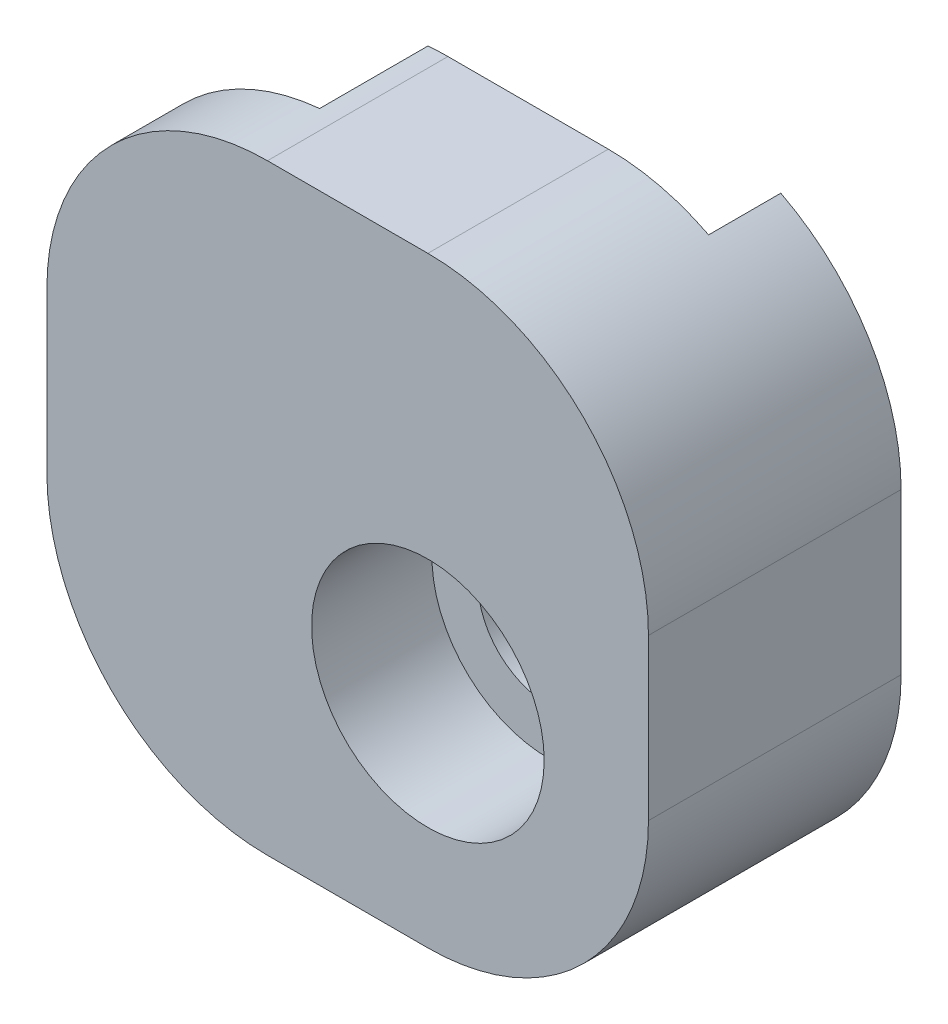
from build123d import *

# Parameters (mm, degrees)
ESBO_O3_W                = 7
ESBO_O3_H                = 12
ESBO_O3_R                = 1.75
RESSALTO_EXTRUS_O2_DEPTH = 2.7
ESBO_O4_W                = 7
ESBO_O4_H                = 12
ESBO_O4_R                = 1.75
RESSALTO_EXTRUS_O3_DEPTH = 2.1
ESBO_O5_W                = 2.1
ESBO_O5_H                = 12
RESSALTO_EXTRUS_O4_DEPTH = 5
RESSALTO_EXTRUS_O5_DEPTH = 3
ESBO_O7_W                = 4.8
ESBO_O7_H                = 15
RESSALTO_EXTRUS_O6_DEPTH = 3
ESBO_O8_R                = 2.9
CORTE_EXTRUS_O1_DEPTH    = 3
FILETE1_R                = 5.5
RESSALTO_EXTRUS_O7_DEPTH = 1.5
CORTE_EXTRUS_O4_DEPTH    = 6.3
CORTE_EXTRUS_O5_DEPTH    = 6.3
RESSALTO_EXTRUS_O8_DEPTH = 0.3
CORTE_EXTRUS_O6_DEPTH    = 0.3
ESBO_O17_R               = 2.9
CORTE_EXTRUS_O7_DEPTH    = 0.3


with BuildPart() as part:
    # Esboço3 → Ressalto-extrusão2 (new body)
    with BuildSketch(Plane.XY):
        with Locations((-3.5, 6)):
            Rectangle(ESBO_O3_W, ESBO_O3_H)
        with Locations((-2.5, 2.5)):
            Circle(ESBO_O3_R, mode=Mode.SUBTRACT)
    extrude(amount=RESSALTO_EXTRUS_O2_DEPTH)

    # Esboço4 → Ressalto-extrusão3 (add)
    with BuildSketch(Plane.XY.offset(2.7)):
        with Locations((-3.5, 6)):
            Rectangle(ESBO_O4_W, ESBO_O4_H)
        with Locations((-2.5, 2.5)):
            Circle(ESBO_O4_R, mode=Mode.SUBTRACT)
    extrude(amount=RESSALTO_EXTRUS_O3_DEPTH)

    # Esboço5 → Ressalto-extrusão4 (add)
    with BuildSketch(Plane.ZY.offset(7)):
        with Locations((3.75, 6)):
            Rectangle(ESBO_O5_W, ESBO_O5_H)
    extrude(amount=RESSALTO_EXTRUS_O4_DEPTH)

    # Esboço6 → Ressalto-extrusão5 (add)
    with BuildSketch(Plane.XZ):
        Polygon((-7, 0), (0, 0), (0, 4.8), (-12, 4.8), (-12, 2.7), (-7, 2.7), align=None)
    extrude(amount=RESSALTO_EXTRUS_O5_DEPTH)

    # Esboço7 → Ressalto-extrusão6 (add)
    with BuildSketch(Plane(origin=(0, 0, 0), x_dir=(0, 0, -1), z_dir=(1, 0, 0))):
        with Locations((-2.4, 4.5)):
            Rectangle(ESBO_O7_W, ESBO_O7_H)
    extrude(amount=RESSALTO_EXTRUS_O6_DEPTH)

    # Esboço8 → Corte-extrusão1 (cut)
    with BuildSketch(Plane.XY.offset(4.8)):
        with Locations((-2.5, 2.5)):
            Circle(ESBO_O8_R)
    extrude(amount=-CORTE_EXTRUS_O1_DEPTH, mode=Mode.SUBTRACT)

    # Filete1
    filete1_edges = [part.edges().sort_by_distance(p)[0] for p in [
        (3, -3, 2.4),
    ]]
    fillet(filete1_edges, radius=FILETE1_R)

    # Esboço10 → Ressalto-extrusão7 (add)
    with BuildSketch(Plane(origin=(0, 0, 0), x_dir=(-1, 0, 0), z_dir=(0, 0, -1))):
        with BuildLine():
            Line((7, 0), (0, 0))
            Line((0, 0), (0, 12))
            Line((0, 12), (-3, 12))
            Line((-3, 12), (-3, 2.5))
            ThreePointArc((-3, 2.5), (-1.389087297, -1.389087297), (2.5, -3))
            Line((2.5, -3), (7, -3))
            Line((7, -3), (7, 0))
        make_face()
    extrude(amount=RESSALTO_EXTRUS_O7_DEPTH)

    # Esboço14 → Corte-extrusão4 (cut)
    with BuildSketch(Plane.XY.offset(4.8)):
        with BuildLine():
            Line((-12, 12), (-12, 6.5))
            ThreePointArc((-12, 6.5), (-10.389087297, 10.389087297), (-6.5, 12))
            Line((-6.5, 12), (-12, 12))
        make_face()
        with BuildLine():
            ThreePointArc((-2.5, 12), (1.389087297, 10.389087297), (3, 6.5))
            Line((3, 6.5), (3, 12))
            Line((3, 12), (-2.5, 12))
        make_face()
    extrude(amount=-CORTE_EXTRUS_O4_DEPTH, mode=Mode.SUBTRACT)

    # Esboço13 → Corte-extrusão5 (cut)
    with BuildSketch(Plane.XY.offset(4.8)):
        with BuildLine():
            Line((-12, -3), (-6.5, -3))
            ThreePointArc((-6.5, -3), (-10.389087297, -1.389087297), (-12, 2.5))
            Line((-12, 2.5), (-12, -3))
        make_face()
    extrude(amount=-CORTE_EXTRUS_O5_DEPTH, mode=Mode.SUBTRACT)

    # Esboço15 → Ressalto-extrusão8 (add)
    with BuildSketch(Plane(origin=(0, 0, -1.5), x_dir=(-1, 0, 0), z_dir=(0, 0, -1))):
        with BuildLine():
            Line((2.5, -3), (6.5, -3))
            ThreePointArc((6.5, -3), (6.750259203, -2.994303444), (7, -2.977225575))
            Line((7, -2.977225575), (7, 0))
            Line((7, 0), (0, 0))
            Line((0, 0), (0, 11.398979486))
            ThreePointArc((0, 11.398979486), (-2.19041576, 9.372281323), (-3, 6.5))
            Line((-3, 6.5), (-3, 2.5))
            ThreePointArc((-3, 2.5), (-1.389087297, -1.389087297), (2.5, -3))
        make_face()
    extrude(amount=RESSALTO_EXTRUS_O8_DEPTH)

    # Esboço16 → Corte-extrusão6 (cut)
    with BuildSketch(Plane.XY.offset(4.8)):
        with BuildLine():
            Line((-12, 6.5), (-12, 2.5))
            ThreePointArc((-12, 2.5), (-10.389087297, -1.389087297), (-6.5, -3))
            Line((-6.5, -3), (-2.5, -3))
            ThreePointArc((-2.5, -3), (1.389087297, -1.389087297), (3, 2.5))
            Line((3, 2.5), (3, 6.5))
            ThreePointArc((3, 6.5), (1.389087297, 10.389087297), (-2.5, 12))
            Line((-2.5, 12), (-6.5, 12))
            ThreePointArc((-6.5, 12), (-10.389087297, 10.389087297), (-12, 6.5))
        make_face()
    extrude(amount=-CORTE_EXTRUS_O6_DEPTH, mode=Mode.SUBTRACT)

    # Esboço17 → Corte-extrusão7 (cut)
    with BuildSketch(Plane.XY.offset(1.8)):
        with Locations((-2.5, 2.5)):
            Circle(ESBO_O17_R)
    extrude(amount=-CORTE_EXTRUS_O7_DEPTH, mode=Mode.SUBTRACT)


solid = part.part
